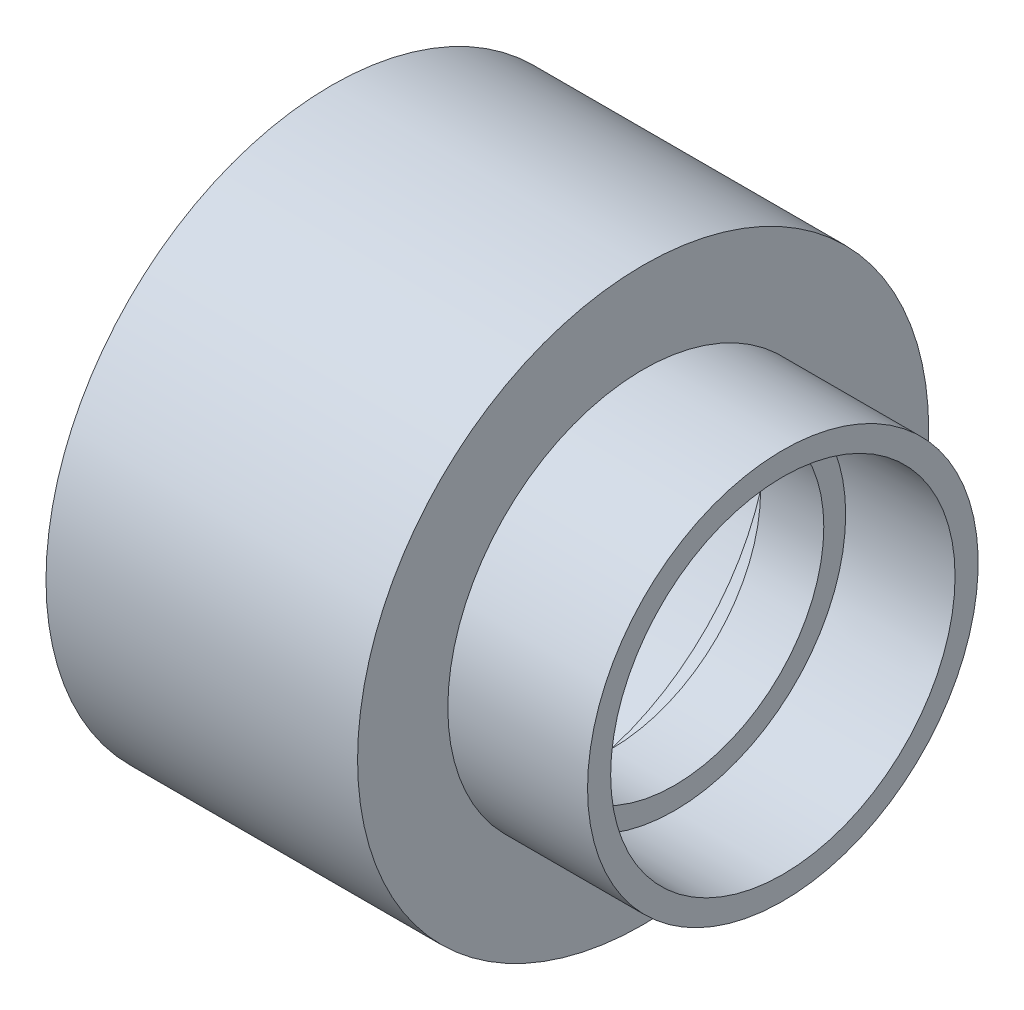
from build123d import *


with BuildPart() as part:
    # Sketch1 → Revolve1 (revolve)
    with BuildSketch(Plane.XY):
        Polygon((-49.2125, -50.2285), (5.588, -50.2285), (5.588, -34.3535), (30.1625, -34.3535), (30.1625, -30.2895), (11.1125, -30.099), (11.1125, -26.2509), (0, -26.2509), (0, -38.9636), (-11.1125, -38.9636), (-11.1125, -44.3865), (-49.2125, -44.6405), align=None)
    revolve(axis=Axis((-49.2125, 0, 0), (1, 0, 0)))


solid = part.part
